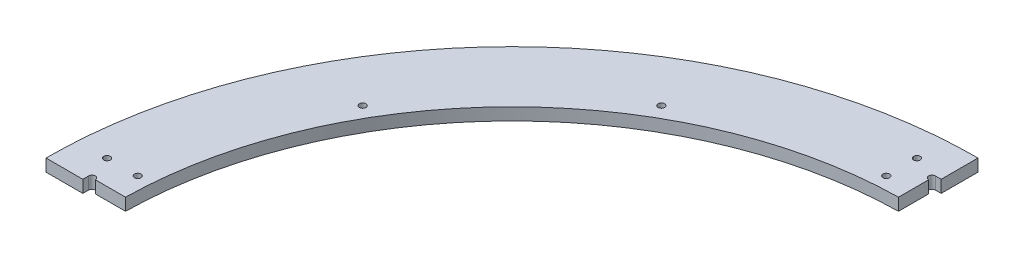
from build123d import *

# Parameters (mm, degrees)
BOSS_EXTRUDE1_DEPTH     = 12.7
SKETCH2_W               = 12.7
SKETCH2_H               = 38.149612403
SKETCH2_W_2             = 38.149612403
SKETCH2_H_2             = 12.7
CUT_EXTRUDE1_DEPTH      = 13.7
SKETCH3_R               = 3.429
CUT_EXTRUDE2_DEPTH      = 13.7
F_1_4_CLEARANCE_HOLE1_D = 6.7564
SKETCH8_W               = 482.6
SKETCH8_H               = 482.6
CUT_EXTRUDE4_DEPTH      = 13.7
SKETCH9_W               = 0.3175
SKETCH9_H               = 38.1
SKETCH9_W_2             = 38.1
SKETCH9_H_2             = 0.3175
CUT_EXTRUDE5_DEPTH      = 13.7


with BuildPart() as part:
    # Sketch1 → Boss-Extrude1 (new body)
    with BuildSketch(Plane(origin=(0, 0, 0), x_dir=(1, 0, 0), z_dir=(0, 1, 0))):
        with BuildLine():
            Line((-406.4, 0), (-482.6, 0))
            ThreePointArc((-482.6, 0), (0, 482.6), (482.6, 0))
            Line((482.6, 0), (406.4, 0))
            ThreePointArc((406.4, 0), (0, 406.4), (-406.4, 0))
        make_face()
    extrude(amount=BOSS_EXTRUDE1_DEPTH)

    # Sketch2 → Cut-Extrude1 (cut, through all)
    with BuildSketch(Plane(origin=(0, 12.7, 0), x_dir=(1, 0, 0), z_dir=(0, 1, 0))):
        with Locations((0, 425.425193799)):
            Rectangle(SKETCH2_W, SKETCH2_H)
        with Locations((425.425193799, 0)):
            Rectangle(SKETCH2_W_2, SKETCH2_H_2)
        with Locations((0, -425.425193799)):
            Rectangle(SKETCH2_W, SKETCH2_H)
        with Locations((-425.425193799, 0)):
            Rectangle(SKETCH2_W_2, SKETCH2_H_2)
    extrude(amount=-CUT_EXTRUDE1_DEPTH, mode=Mode.SUBTRACT)

    # Sketch3 → Cut-Extrude2 (cut, through all)
    with BuildSketch(Plane(origin=(0, 12.7, 0), x_dir=(1, 0, 0), z_dir=(0, 1, 0))):
        with Locations((-6.35, 441.071)):
            Circle(SKETCH3_R)
        with Locations((-441.071, 6.35)):
            Circle(SKETCH3_R)
        with Locations((6.35, 441.071)):
            Circle(SKETCH3_R)
        with Locations((441.071, 6.35)):
            Circle(SKETCH3_R)
    extrude(amount=-CUT_EXTRUDE2_DEPTH, mode=Mode.SUBTRACT)

    # 1/4 Clearance Hole1 (through all)
    with Locations(Plane(origin=(0, 12.7, 0), x_dir=(1, 0, 0), z_dir=(0, 1, 0))):
        with Locations((-365.700877383, 211.1375), (-31.75, 419.1), (-31.75, 450.85), (-419.1, 31.75), (-450.85, 31.75), (-211.1375, 365.700877383)):
            Hole(F_1_4_CLEARANCE_HOLE1_D / 2)

    # Sketch8 → Cut-Extrude4 (cut, through all)
    with BuildSketch(Plane(origin=(0, 12.7, 0), x_dir=(1, 0, 0), z_dir=(0, 1, 0))):
        with Locations((241.3, 241.3)):
            Rectangle(SKETCH8_W, SKETCH8_H)
    extrude(amount=-CUT_EXTRUDE4_DEPTH, mode=Mode.SUBTRACT)

    # Sketch9 → Cut-Extrude5 (cut, through all)
    with BuildSketch(Plane(origin=(0, 12.7, 0), x_dir=(1, 0, 0), z_dir=(0, 1, 0))):
        with Locations((-0.15875, 463.55)):
            Rectangle(SKETCH9_W, SKETCH9_H)
        with Locations((-463.55, 0.15875)):
            Rectangle(SKETCH9_W_2, SKETCH9_H_2)
    extrude(amount=-CUT_EXTRUDE5_DEPTH, mode=Mode.SUBTRACT)


solid = part.part
